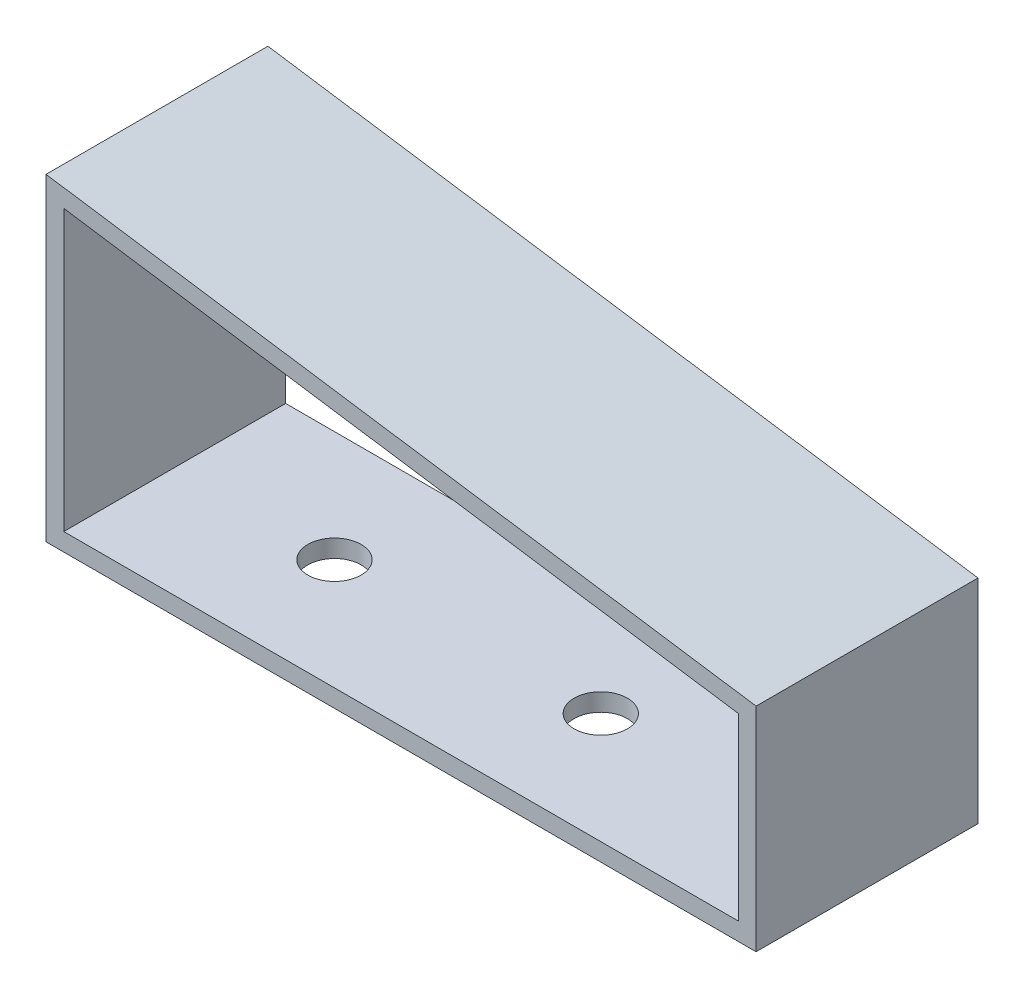
from build123d import *

# Parameters (mm, degrees)
BOSS_EXTRUDE1_DEPTH = 25
SKETCH4_R           = 3
CUT_EXTRUDE1_DEPTH  = 17


with BuildPart() as part:
    # Sketch3 → Boss-Extrude1 (new body)
    with BuildSketch(Plane.XY):
        Polygon((0, 35.853266996), (0, 0), (80, 0), (80, 23.970502896), align=None)
        Polygon((2, 33.534255745), (2, 2), (78, 2), (78, 22.24562985), align=None, mode=Mode.SUBTRACT)
    extrude(amount=BOSS_EXTRUDE1_DEPTH)

    # Sketch4 → Cut-Extrude1 (cut)
    with BuildSketch(Plane.XZ):
        with Locations((20, 12.5)):
            Circle(SKETCH4_R)
        with Locations((50, 12.5)):
            Circle(SKETCH4_R)
    extrude(amount=-CUT_EXTRUDE1_DEPTH, mode=Mode.SUBTRACT)


solid = part.part
